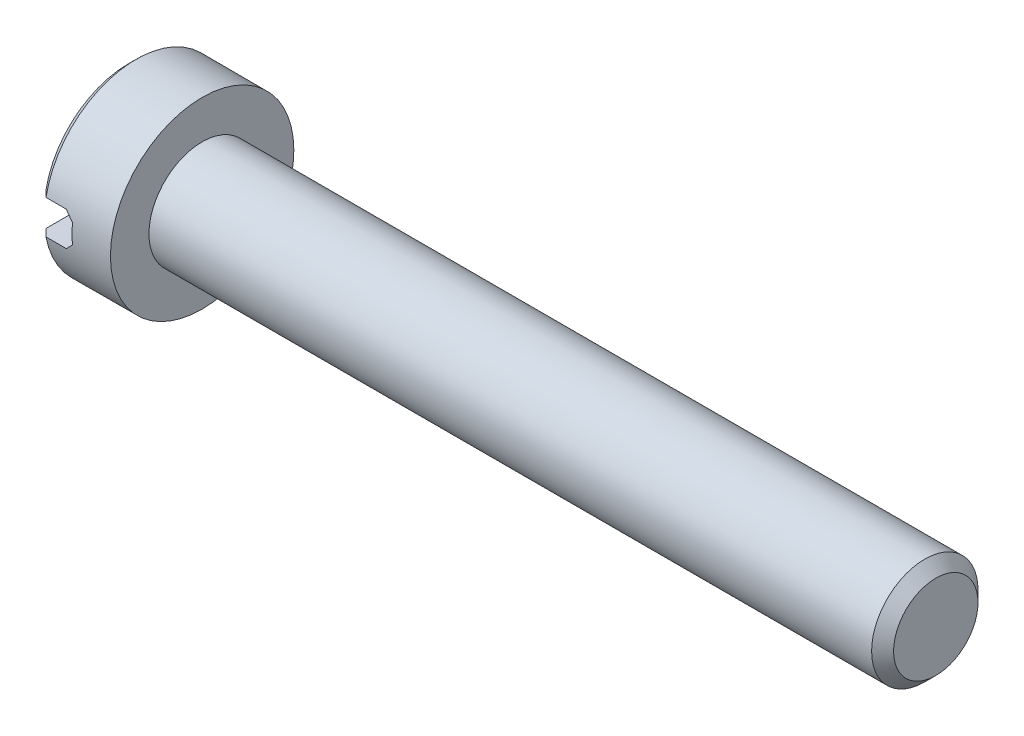
from build123d import *

# Parameters (mm, degrees)
ENL_V_MAT_EXTRU_1_DEPTH = 5
ESQUISSE3_R             = 1.45
EXTRUSION1_DEPTH        = 20
CHANFREIN1_SIZE         = 0.3


with BuildPart() as part:
    # Esquisse1 → Révolution1 (revolve)
    with BuildSketch(Plane.XY, mode=Mode.PRIVATE) as r_volution1_sk:
        Polygon((0, 0), (0, 2.3), (0.2, 2.5), (2, 2.5), (2, 0), align=None)
    revolve(r_volution1_sk.sketch.rotate(Axis((0, 0, 0), (1, 0, 0)), 90), axis=Axis((0, 0, 0), (1, 0, 0)))  # turned: the seam where the file's is

    # Esquisse2 → Enlèv. mat.-Extru.1 (cut, symmetric)
    with BuildSketch(Plane.XY):
        Polygon((0, 0.465549348), (0.753445065, 0.465549348), (0.953445065, 0.265549348), (0.953445065, -0.265549348), (0.753445065, -0.465549348), (0, -0.465549348), align=None)
    extrude(amount=ENL_V_MAT_EXTRU_1_DEPTH, both=True, mode=Mode.SUBTRACT)

    # Esquisse3 → Extrusion1 (add)
    with BuildSketch(Plane(origin=(2, 0, 0), x_dir=(0, 0, -1), z_dir=(1, 0, 0))):
        with Locations(Location((0, 0, 0), (0, 0, 180))):  # turned: the seam where the file's is
            Circle(ESQUISSE3_R)
    extrude(amount=EXTRUSION1_DEPTH)

    # Chanfrein1
    chanfrein1_edges = [part.edges().sort_by_distance(p)[0] for p in [
        (22, 0, -1.45),
    ]]
    chamfer(chanfrein1_edges, length=CHANFREIN1_SIZE)


solid = part.part
